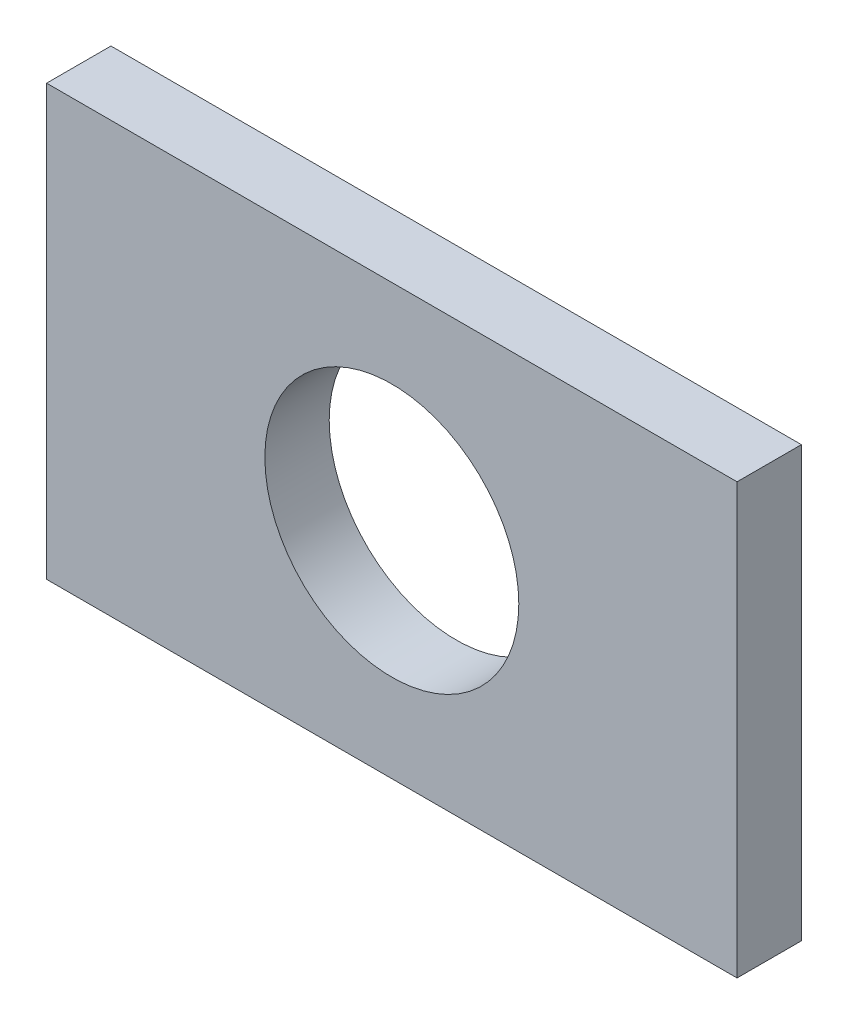
from build123d import *

# Parameters (mm, degrees)
ESQUISSE1_W             = 107.294030568
ESQUISSE1_H             = 66.778372094
BOSS_EXTRU_1_DEPTH      = 10
ESQUISSE2_R             = 19.731797857
ENL_V_MAT_EXTRU_1_DEPTH = 10


with BuildPart() as part:
    # Esquisse1 → Boss.-Extru.1 (new body)
    with BuildSketch(Plane.XY):
        Rectangle(ESQUISSE1_W, ESQUISSE1_H)
    extrude(amount=BOSS_EXTRU_1_DEPTH)

    # Esquisse2 → Enlèv. mat.-Extru.1 (cut)
    with BuildSketch(Plane.XY.offset(10)):
        Circle(ESQUISSE2_R)
    extrude(amount=-ENL_V_MAT_EXTRU_1_DEPTH, mode=Mode.SUBTRACT)


solid = part.part
